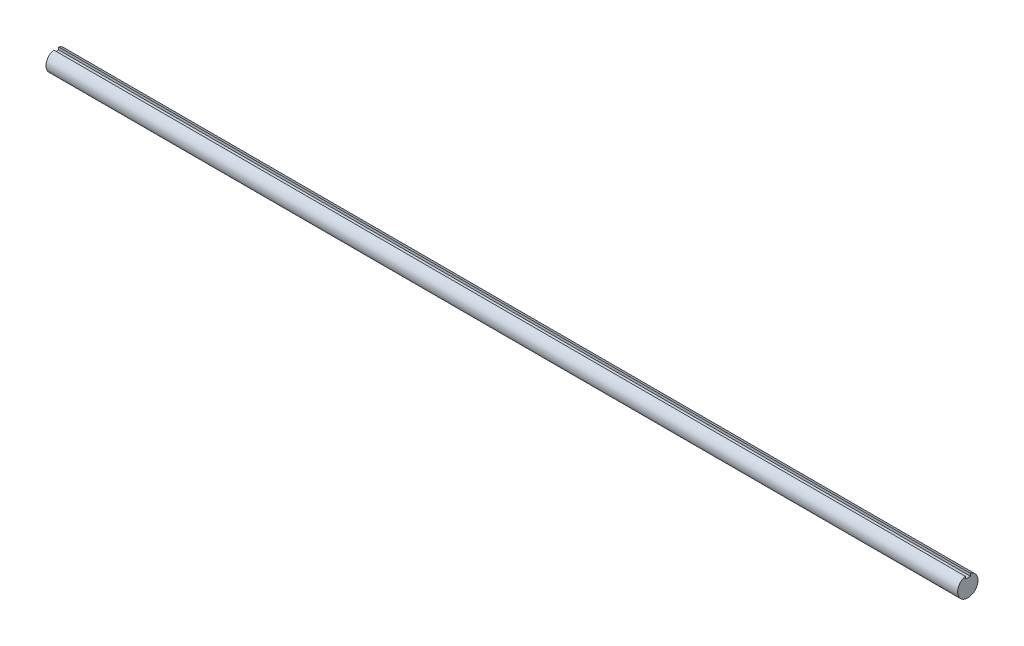
from build123d import *

# Parameters (mm, degrees)
BOSS_EXTRUDE1_DEPTH = 284.1625


with BuildPart() as part:
    # Sketch1 → Boss-Extrude1 (new body, symmetric)
    with BuildSketch(Plane(origin=(0, 0, 0), x_dir=(0, 0, -1), z_dir=(1, 0, 0))):
        with BuildLine():
            Line((-1.5875, 6.148361062), (-1.5875, 4.560861062))
            Line((-1.5875, 4.560861062), (1.5875, 4.560861062))
            Line((1.5875, 4.560861062), (1.5875, 6.148361062))
            ThreePointArc((1.5875, 6.148361062), (0, -6.35), (-1.5875, 6.148361062))
        make_face()
    extrude(amount=BOSS_EXTRUDE1_DEPTH, both=True)


solid = part.part
